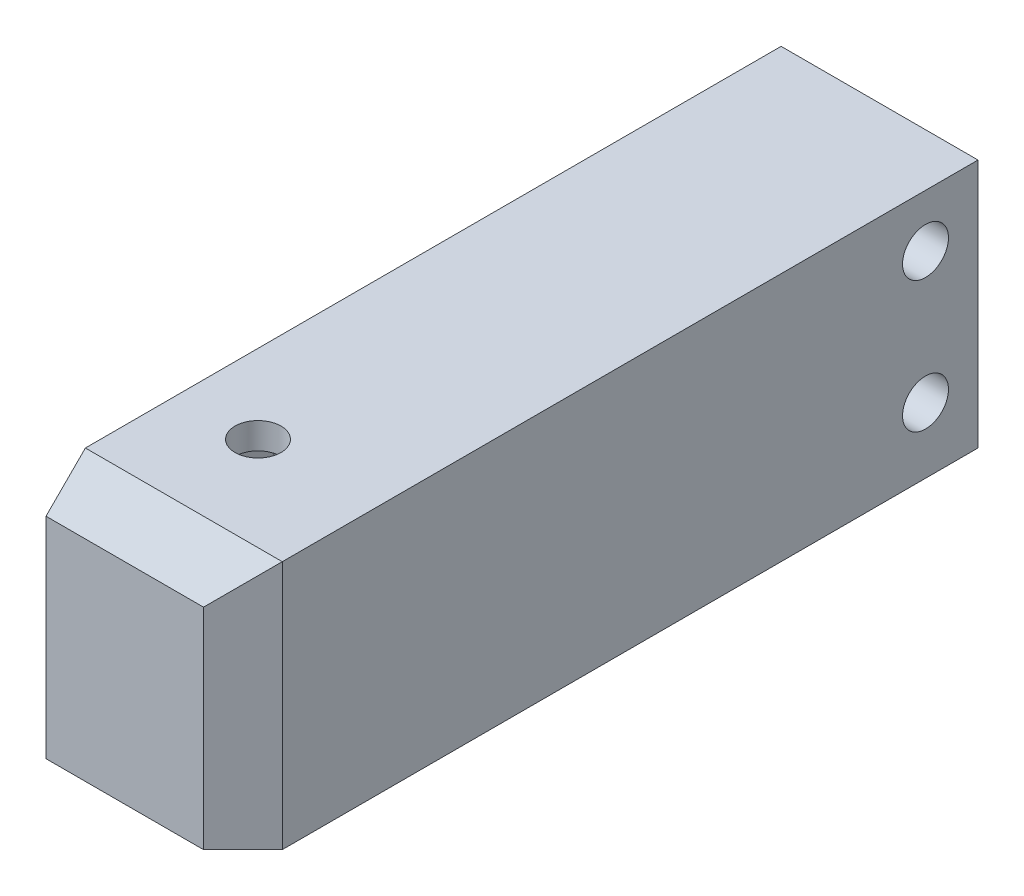
from build123d import *

# Parameters (mm, degrees)
CROQUIS1_W              = 19
CROQUIS1_H              = 56
SALIENTE_EXTRUIR1_DEPTH = 15
CHAFL_N1_SIZE           = 3
CROQUIS2_W              = 12.5
CROQUIS2_H              = 24
CORTAR_EXTRUIR1_DEPTH   = 15
CROQUIS3_R              = 1
CORTAR_EXTRUIR2_DEPTH   = 15
CROQUIS8_R              = 1
CORTAR_EXTRUIR3_DEPTH   = 15
CROQUIS9_R              = 1.75
CORTAR_EXTRUIR4_DEPTH   = 16
CORTAR_EXTRUIR5_REACH   = 17
CROQUIS10_R             = 1.75
CROQUIS11_R             = 1.75
CORTAR_EXTRUIR6_DEPTH   = 20
CROQUIS12_R             = 1.75
CORTAR_EXTRUIR7_DEPTH   = 2


with BuildPart() as part:
    # Croquis1 → Saliente-Extruir1 (new body)
    with BuildSketch(Plane(origin=(-177, 0, 0), x_dir=(0, -1, 0), z_dir=(-1, 0, 0))):
        with Locations((-56.5, 110.5)):
            Rectangle(CROQUIS1_W, CROQUIS1_H)
    extrude(amount=-SALIENTE_EXTRUIR1_DEPTH)

    # Chaflán1
    chafl_n1_edges = [part.edges().sort_by_distance(p)[0] for p in [
        (-162, 56.5, 138.5),
        (-169.5, 66, 138.5),
    ]]
    chamfer(chafl_n1_edges, length=CHAFL_N1_SIZE)

    # Croquis2 → Cortar-Extruir1 (cut)
    with BuildSketch(Plane.XZ.offset(-47)):
        with Locations((-170.75, 122.5)):
            Rectangle(CROQUIS2_W, CROQUIS2_H)
    extrude(amount=-CORTAR_EXTRUIR1_DEPTH, mode=Mode.SUBTRACT)

    # Croquis3 → Cortar-Extruir2 (cut)
    with BuildSketch(Plane.XZ.offset(-47)):
        with Locations((-171, 136.25)):
            Circle(CROQUIS3_R)
    extrude(amount=-CORTAR_EXTRUIR2_DEPTH, mode=Mode.SUBTRACT)

    # Croquis8 → Cortar-Extruir3 (cut)
    with BuildSketch(Plane(origin=(0, 47, 0), x_dir=(-1, 0, 0), z_dir=(0, -1, 0))):
        with Locations((171, -108.75)):
            Circle(CROQUIS8_R)
    extrude(amount=-CORTAR_EXTRUIR3_DEPTH, mode=Mode.SUBTRACT)

    # Croquis9 → Cortar-Extruir4 (cut, through all)
    with BuildSketch(Plane(origin=(-162, 0, 0), x_dir=(0, 0, -1), z_dir=(1, 0, 0))):
        with Locations((-86.5, 52)):
            Circle(CROQUIS9_R)
    extrude(amount=-CORTAR_EXTRUIR4_DEPTH, mode=Mode.SUBTRACT)

    # Croquis10 → Cortar-Extruir5 (cut, up to next)
    with BuildSketch(Plane(origin=(-162, 0, 0), x_dir=(0, 0, -1), z_dir=(1, 0, 0)), mode=Mode.PRIVATE) as cortar_extruir5_sk1:
        with Locations((-86.5, 62)):
            Circle(CROQUIS10_R)
    cortar_extruir5_tool1 = extrude(cortar_extruir5_sk1.sketch, amount=-CORTAR_EXTRUIR5_REACH, mode=Mode.PRIVATE) & part.part
    add(cortar_extruir5_tool1.solids().sort_by_distance((-162, 62, 86.5))[0], mode=Mode.SUBTRACT)

    # Croquis11 → Cortar-Extruir6 (cut, through all)
    with BuildSketch(Plane(origin=(0, 66, 0), x_dir=(-1, 0, 0), z_dir=(0, 1, 0))):
        with Locations((171, 128.35)):
            Circle(CROQUIS11_R)
    extrude(amount=-CORTAR_EXTRUIR6_DEPTH, mode=Mode.SUBTRACT)

    # Croquis12 → Cortar-Extruir7 (cut)
    with BuildSketch(Plane.XZ.offset(-62)):
        Polygon((-172.65, 125.492116168), (-169.35, 125.492116168), (-167.7, 128.35), (-169.35, 131.207883832), (-172.65, 131.207883832), (-174.3, 128.35), align=None)
        with Locations((-171, 128.35)):
            Circle(CROQUIS12_R, mode=Mode.SUBTRACT)
    extrude(amount=-CORTAR_EXTRUIR7_DEPTH, mode=Mode.SUBTRACT)


solid = part.part
